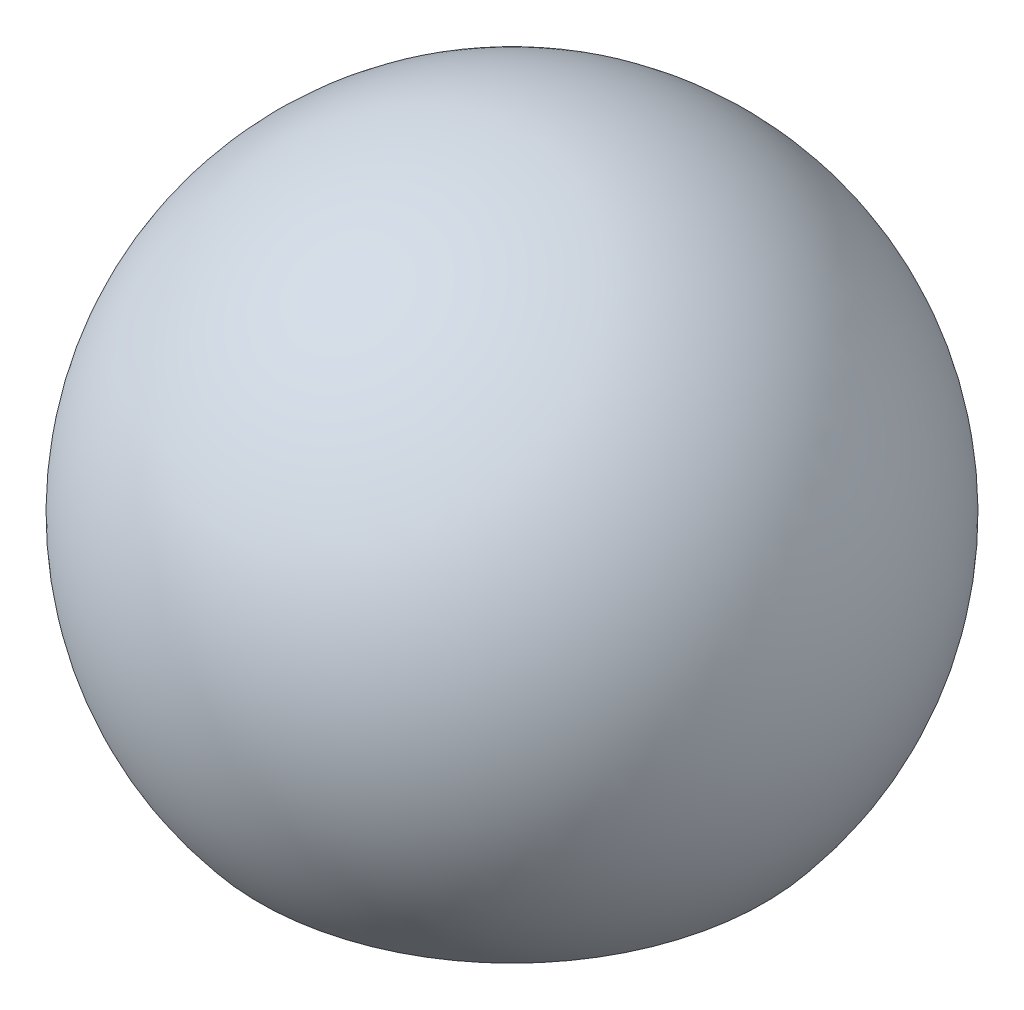
from build123d import *


with BuildPart() as part:
    # Sketch2 → Revolve1 (revolve)
    with BuildSketch(Plane.XY):
        with BuildLine():
            Line((0, 1300), (0, 2300))
            ThreePointArc((0, 2300), (1540.723237962, 1318.451044959), (1302.275553302, -492.738936467))
            Line((1302.275553302, -492.738936467), (536.231110183, 150.048673219))
            ThreePointArc((536.231110183, 150.048673219), (634.415450926, 895.832783218), (0, 1300))
        make_face()
    revolve(axis=Axis((0, 700, 0), (0, 1, 0)))


solid = part.part
